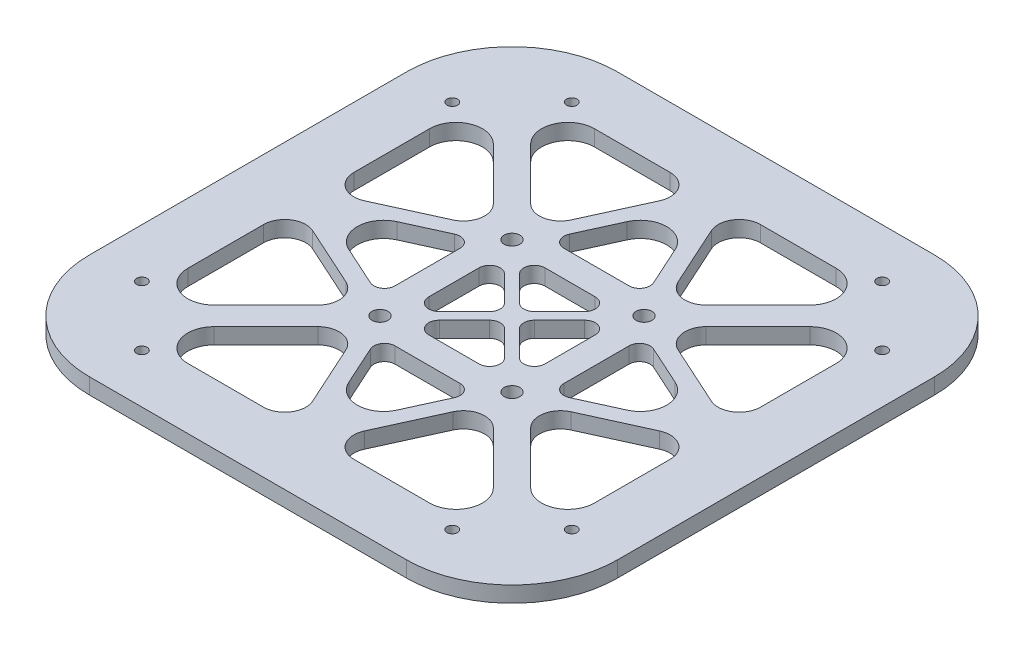
from build123d import *

# Parameters (mm, degrees)
ESQUISSE1_W        = 100
ESQUISSE1_H        = 100
ESQUISSE1_R        = 1.5
ESQUISSE1_R_2      = 1
BOSS_EXTRU_1_DEPTH = 3
CONG_1_R           = 20
CONG_2_R           = 5
CONG_3_R           = 4
CONG_4_R           = 2


with BuildPart() as part:
    # Esquisse1 → Boss.-Extru.1 (new body)
    with BuildSketch(Plane(origin=(0, 0, 0), x_dir=(1, 0, 0), z_dir=(0, 1, 0))):
        Rectangle(ESQUISSE1_W, ESQUISSE1_H)
        with Locations((-12.5, -12.5)):
            Circle(ESQUISSE1_R, mode=Mode.SUBTRACT)
        with Locations((12.5, -12.5)):
            Circle(ESQUISSE1_R, mode=Mode.SUBTRACT)
        with Locations((-12.5, 12.5)):
            Circle(ESQUISSE1_R, mode=Mode.SUBTRACT)
        with Locations((12.5, 12.5)):
            Circle(ESQUISSE1_R, mode=Mode.SUBTRACT)
        with Locations((40.707106781, -29.393398282)):
            Circle(ESQUISSE1_R_2, mode=Mode.SUBTRACT)
        with Locations((29.393398282, -40.707106781)):
            Circle(ESQUISSE1_R_2, mode=Mode.SUBTRACT)
        with Locations((-29.393398282, -40.707106781)):
            Circle(ESQUISSE1_R_2, mode=Mode.SUBTRACT)
        with Locations((-40.707106781, -29.393398282)):
            Circle(ESQUISSE1_R_2, mode=Mode.SUBTRACT)
        with Locations((-40.707106781, 29.393398282)):
            Circle(ESQUISSE1_R_2, mode=Mode.SUBTRACT)
        with Locations((-29.393398282, 40.707106781)):
            Circle(ESQUISSE1_R_2, mode=Mode.SUBTRACT)
        with Locations((29.393398282, 40.707106781)):
            Circle(ESQUISSE1_R_2, mode=Mode.SUBTRACT)
        with Locations((40.707106781, 29.393398282)):
            Circle(ESQUISSE1_R_2, mode=Mode.SUBTRACT)
        Polygon((-9.261402822, -16), (0, -36.375086208), (9.261402822, -16), align=None, mode=Mode.SUBTRACT)
        Polygon((0, -1.414213562), (-9.585786438, -11), (9.585786438, -11), align=None, mode=Mode.SUBTRACT)
        Polygon((-34.964466094, -38.5), (-2.329506269, -38.5), (-12.527931214, -16.06346512), align=None, mode=Mode.SUBTRACT)
        Polygon((34.964466094, -38.5), (2.329506269, -38.5), (12.527931214, -16.06346512), align=None, mode=Mode.SUBTRACT)
        Polygon((-16, 9.261402822), (-36.375086208, 0), (-16, -9.261402822), align=None, mode=Mode.SUBTRACT)
        Polygon((-1.414213562, 0), (-11, 9.585786438), (-11, -9.585786438), align=None, mode=Mode.SUBTRACT)
        Polygon((-38.5, 34.964466094), (-38.5, 2.329506269), (-16.06346512, 12.527931214), align=None, mode=Mode.SUBTRACT)
        Polygon((-38.5, -34.964466094), (-38.5, -2.329506269), (-16.06346512, -12.527931214), align=None, mode=Mode.SUBTRACT)
        Polygon((9.261402822, 16), (0, 36.375086208), (-9.261402822, 16), align=None, mode=Mode.SUBTRACT)
        Polygon((0, 1.414213562), (9.585786438, 11), (-9.585786438, 11), align=None, mode=Mode.SUBTRACT)
        Polygon((34.964466094, 38.5), (2.329506269, 38.5), (12.527931214, 16.06346512), align=None, mode=Mode.SUBTRACT)
        Polygon((-34.964466094, 38.5), (-2.329506269, 38.5), (-12.527931214, 16.06346512), align=None, mode=Mode.SUBTRACT)
        Polygon((16, -9.261402822), (36.375086208, 0), (16, 9.261402822), align=None, mode=Mode.SUBTRACT)
        Polygon((1.414213562, 0), (11, -9.585786438), (11, 9.585786438), align=None, mode=Mode.SUBTRACT)
        Polygon((38.5, -34.964466094), (38.5, -2.329506269), (16.06346512, -12.527931214), align=None, mode=Mode.SUBTRACT)
        Polygon((38.5, 34.964466094), (38.5, 2.329506269), (16.06346512, 12.527931214), align=None, mode=Mode.SUBTRACT)
    extrude(amount=BOSS_EXTRU_1_DEPTH)

    # Congé1
    cong_1_edges = [part.edges().sort_by_distance(p)[0] for p in [
        (-50, 1.5, -50),
        (50, 1.5, -50),
        (50, 1.5, 50),
        (-50, 1.5, 50),
    ]]
    fillet(cong_1_edges, radius=CONG_1_R)

    # Congé2
    cong_2_edges = [part.edges().sort_by_distance(p)[0] for p in [
        (0, 1.5, -36.375086208),
        (34.964466094, 1.5, -38.5),
        (-34.964466094, 1.5, -38.5),
        (36.375086208, 1.5, 0),
        (38.5, 1.5, 34.964466094),
        (38.5, 1.5, -34.964466094),
        (0, 1.5, 36.375086208),
        (-34.964466094, 1.5, 38.5),
        (34.964466094, 1.5, 38.5),
        (-36.375086208, 1.5, 0),
        (-38.5, 1.5, -34.964466094),
        (-38.5, 1.5, 34.964466094),
    ]]
    fillet(cong_2_edges, radius=CONG_2_R)

    # Congé3
    cong_3_edges = [part.edges().sort_by_distance(p)[0] for p in [
        (12.527931214, 1.5, -16.06346512),
        (2.329506269, 1.5, -38.5),
        (-12.527931214, 1.5, -16.06346512),
        (-2.329506269, 1.5, -38.5),
        (16.06346512, 1.5, 12.527931214),
        (38.5, 1.5, 2.329506269),
        (16.06346512, 1.5, -12.527931214),
        (38.5, 1.5, -2.329506269),
        (-12.527931214, 1.5, 16.06346512),
        (-2.329506269, 1.5, 38.5),
        (12.527931214, 1.5, 16.06346512),
        (2.329506269, 1.5, 38.5),
        (-16.06346512, 1.5, -12.527931214),
        (-38.5, 1.5, -2.329506269),
        (-16.06346512, 1.5, 12.527931214),
        (-38.5, 1.5, 2.329506269),
    ]]
    fillet(cong_3_edges, radius=CONG_3_R)

    # Congé4
    cong_4_edges = [part.edges().sort_by_distance(p)[0] for p in [
        (-9.585786438, 1.5, -11),
        (0, 1.5, -1.414213562),
        (9.585786438, 1.5, -11),
        (-9.261402822, 1.5, -16),
        (9.261402822, 1.5, -16),
        (9.585786438, 1.5, 11),
        (0, 1.5, 1.414213562),
        (11, 1.5, -9.585786438),
        (1.414213562, 1.5, 0),
        (11, 1.5, 9.585786438),
        (-9.585786438, 1.5, 11),
        (16, 1.5, -9.261402822),
        (16, 1.5, 9.261402822),
        (9.261402822, 1.5, 16),
        (-9.261402822, 1.5, 16),
        (-11, 1.5, 9.585786438),
        (-1.414213562, 1.5, 0),
        (-11, 1.5, -9.585786438),
        (-16, 1.5, 9.261402822),
        (-16, 1.5, -9.261402822),
    ]]
    fillet(cong_4_edges, radius=CONG_4_R)


solid = part.part
